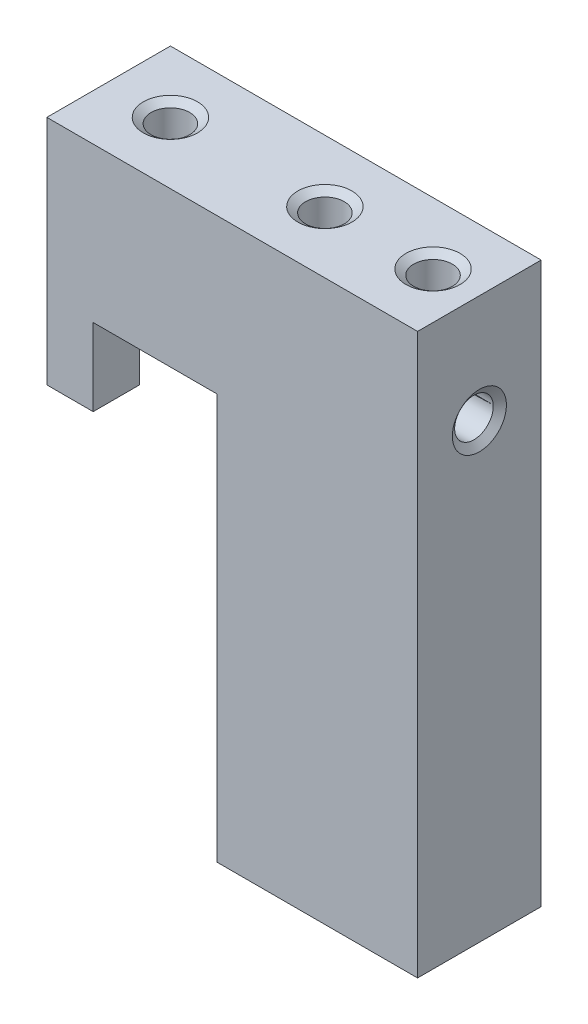
from build123d import *

# Parameters (mm, degrees)
SKETCH_1_W                  = 24
SKETCH_1_H                  = 36.25
EXTRUDE_1_DEPTH             = 8
CUT_EXTRUDE_1_DEPTH         = 9
HOLE_WIZARD_M31_D           = 2.5
HOLE_WIZARD_M31_DEPTH       = 10.5
HOLE_WIZARD_M31_CSINK_D     = 3.2
HOLE_WIZARD_M31_CSINK_ANGLE = 110
HOLE_WIZARD_M31_TIP         = 0.751075774
HOLE_WIZARD_M33_D           = 2.5
HOLE_WIZARD_M33_DEPTH       = 7
HOLE_WIZARD_M33_CSINK_D     = 3.5
HOLE_WIZARD_M33_CSINK_ANGLE = 110
HOLE_WIZARD_M33_TIP         = 0.751075774
CUT_EXTRUDE_4_DEPTH         = 5


with BuildPart() as part:
    # Эскиз1 → Бобышка-Вытянуть1 (new body)
    with BuildSketch(Plane.XY):
        with Locations((12, 18.125)):
            Rectangle(SKETCH_1_W, SKETCH_1_H)
    extrude(amount=EXTRUDE_1_DEPTH)

    # Эскиз2 → Вырез-Вытянуть1 (cut, through all)
    with BuildSketch(Plane.XY.offset(8)):
        Polygon((-87.021101005, 21.25), (0, 21.25), (3, 21.25), (3, 26.25), (11, 26.25), (11, 0), (11, -87.021101005), (-118.022033053, -203.828648138), (-216.043134058, -95.557547133), align=None)
    extrude(amount=-CUT_EXTRUDE_1_DEPTH, mode=Mode.SUBTRACT)

    # Отверстие обработанное метчиком M31
    with Locations(Plane.XZ):
        with Locations((15, 4), (20, 4)):
            CounterSinkHole(HOLE_WIZARD_M31_D / 2, HOLE_WIZARD_M31_CSINK_D / 2, depth=HOLE_WIZARD_M31_DEPTH, counter_sink_angle=HOLE_WIZARD_M31_CSINK_ANGLE)
            with Locations((0, 0, -(HOLE_WIZARD_M31_DEPTH + HOLE_WIZARD_M31_TIP / 2))):  # 118° drill point
                Cone(0, HOLE_WIZARD_M31_D / 2, HOLE_WIZARD_M31_TIP, mode=Mode.SUBTRACT)

    # Эскиз6 → Отверстие обработанное метчиком M32 (revolve, cut)
    with BuildSketch(Plane(origin=(0, 29.25, 4), x_dir=(0, 0, 1), z_dir=(0, 1, 0))):
        Polygon((0, 0), (0, 24), (1.75, 24), (1.25, 23.649896231), (1.25, 0.350103769), (1.75, 0), align=None)
    revolve(axis=Axis((-6.35, 29.25, 4), (1, 0, 0)), mode=Mode.SUBTRACT)

    # Отверстие обработанное метчиком M33
    with Locations(Plane(origin=(0, 36.25, 0), x_dir=(-1, 0, 0), z_dir=(0, 1, 0))):
        with Locations((-14, 4), (-4, 4), (-21, 4)):
            CounterSinkHole(HOLE_WIZARD_M33_D / 2, HOLE_WIZARD_M33_CSINK_D / 2, depth=HOLE_WIZARD_M33_DEPTH, counter_sink_angle=HOLE_WIZARD_M33_CSINK_ANGLE)
            with Locations((0, 0, -(HOLE_WIZARD_M33_DEPTH + HOLE_WIZARD_M33_TIP / 2))):  # 118° drill point
                Cone(0, HOLE_WIZARD_M33_D / 2, HOLE_WIZARD_M33_TIP, mode=Mode.SUBTRACT)

    # Эскиз11 → Вырез-Вытянуть4 (cut)
    with BuildSketch(Plane(origin=(0, 0, 0), x_dir=(-1, 0, 0), z_dir=(0, 0, -1))):
        with BuildLine():
            ThreePointArc((-10.5, 26.25), (-13.118033989, 26.486067977), (-14.5, 24.25))
            Line((-14.5, 24.25), (-14.5, 23.25))
            ThreePointArc((-14.5, 23.25), (-13.767766953, 21.482233047), (-12, 20.75))
            Line((-12, 20.75), (-12, 0))
            Line((-12, 0), (-11, 0))
            Line((-11, 0), (-11, 26.25))
            Line((-11, 26.25), (-10.5, 26.25))
        make_face()
        Polygon((-0.459002775, 23.25), (-3, 25.029225411), (-3, 21.25), (0, 21.25), (0, 23.25), align=None)
    extrude(amount=-CUT_EXTRUDE_4_DEPTH, mode=Mode.SUBTRACT)


solid = part.part
